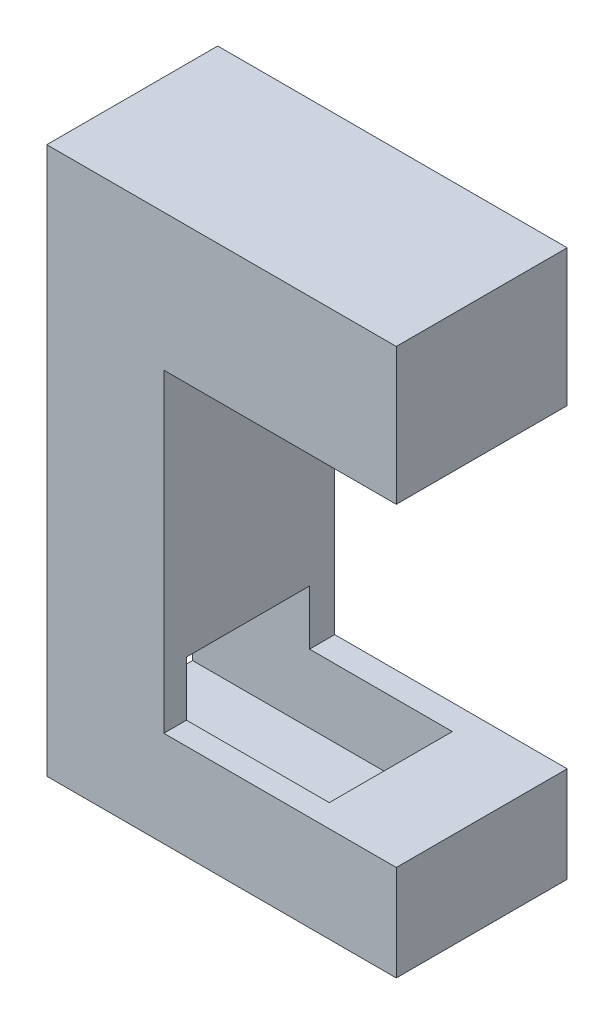
from build123d import *

# Parameters (mm, degrees)
BOSS_EXTRUDE1_DEPTH = 12.5
SKETCH6_W           = 9
SKETCH6_H           = 9
CUT_EXTRUDE2_DEPTH  = 19


with BuildPart() as part:
    # Sketch3 → Boss-Extrude1 (new body)
    with BuildSketch(Plane.XY):
        Polygon((51.444398057, 20.442826613), (25.886157296, 20.442826613), (25.886157296, -19.557173387), (51.444398057, -19.557173387), (51.444398057, -12.557173387), (34.444398057, -12.557173387), (34.444398057, 10.442826613), (51.444398057, 10.442826613), align=None)
    extrude(amount=BOSS_EXTRUDE1_DEPTH)

    # Sketch6 → Cut-Extrude2 (cut)
    with BuildSketch(Plane.ZY.offset(-25.886157296)):
        with Locations((6.342638548, -13.057173387)):
            Rectangle(SKETCH6_W, SKETCH6_H)
    extrude(amount=-CUT_EXTRUDE2_DEPTH, mode=Mode.SUBTRACT)


solid = part.part
